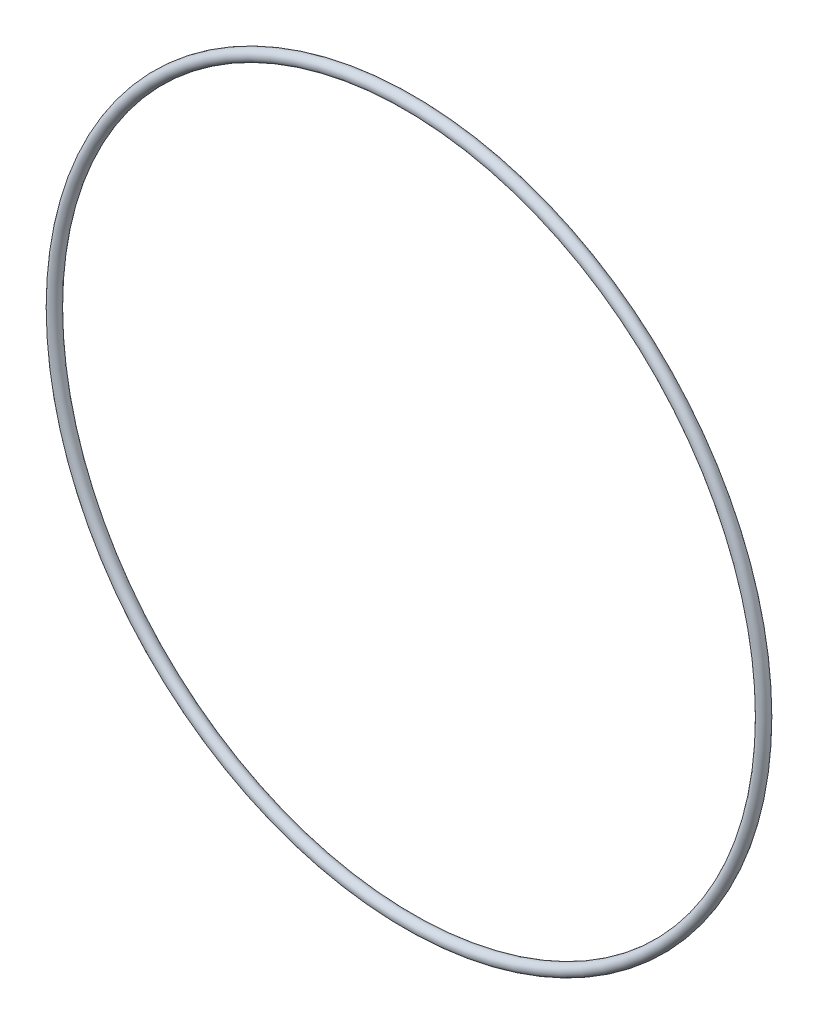
from build123d import *

# Parameters (mm, degrees)
SWEEP1_PROFILE_R = 0.5


with BuildPart() as part:
    # Sweep1: sweep along a path in Sketch1
    with BuildLine(Plane.XY) as sweep1_path:
        CenterArc((0, 0), 30.5, 0, 360)
    # Sweep1 profile (on start of the path) → Sweep1 (sweep)
    with BuildSketch(Plane(origin=(30.5, 0, 0), x_dir=(0, 0, 1), z_dir=(0, 1, 0))):
        Circle(SWEEP1_PROFILE_R)
    sweep(path=sweep1_path.line)


solid = part.part
